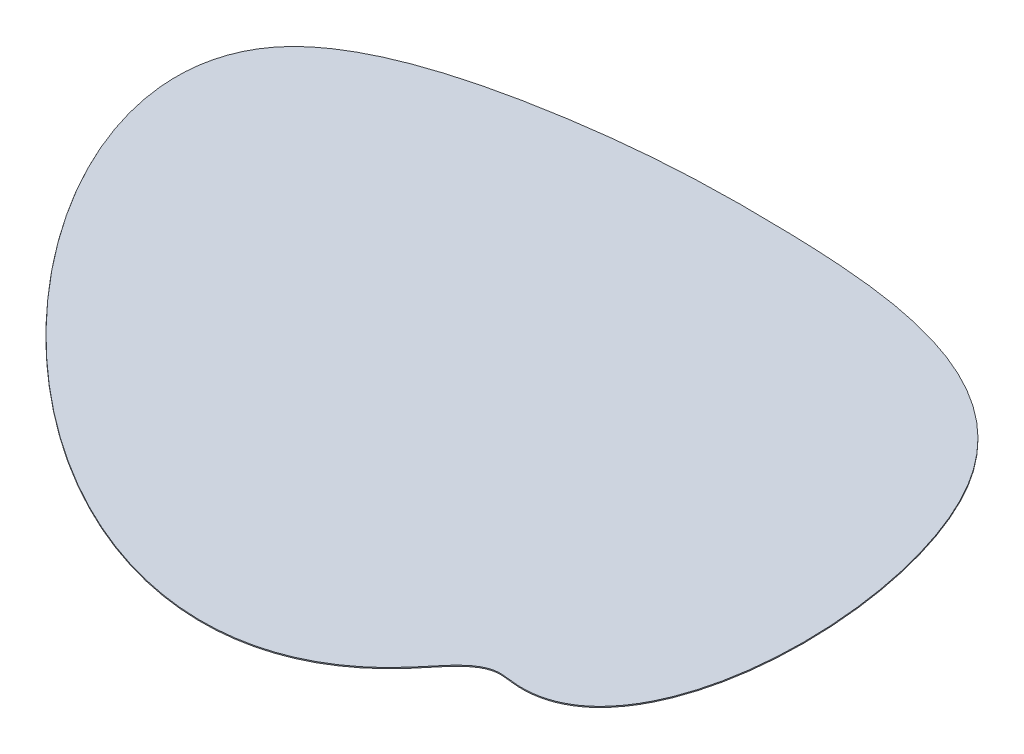
from build123d import *

# Parameters (mm, degrees)
EXTRUDE_1_DEPTH = 10


with BuildPart() as part:
    # 草图1 → 凸台-拉伸1 (new body)
    with BuildSketch(Plane(origin=(0, 0, 0), x_dir=(1, 0, 0), z_dir=(0, 1, 0))):
        with BuildLine():
            add(Edge.make_bspline(
                [(0, 2754.012029644), (1092.783841735, 2723.635418634), (3840.801065666, 2436.698202049), (3779.993864305, -2678.699722511), (2134.206027785, -2380.452213673), (1017.350556237, -4130.041678539), (-2858.206780519, -2681.262509628), (-5353.884086776, 1853.363578645), (-2053.017195884, 2727.091553331), (-742.852763111, 2774.661446812), (0, 2754.012029644)],
                knots=[0, 0, 0, 0, 0.155060274, 0.346396883, 0.353891126, 0.383558883, 0.594984115, 0.796729325, 0.894593104, 1, 1, 1, 1], degree=3))
        make_face()
    extrude(amount=EXTRUDE_1_DEPTH)


solid = part.part
